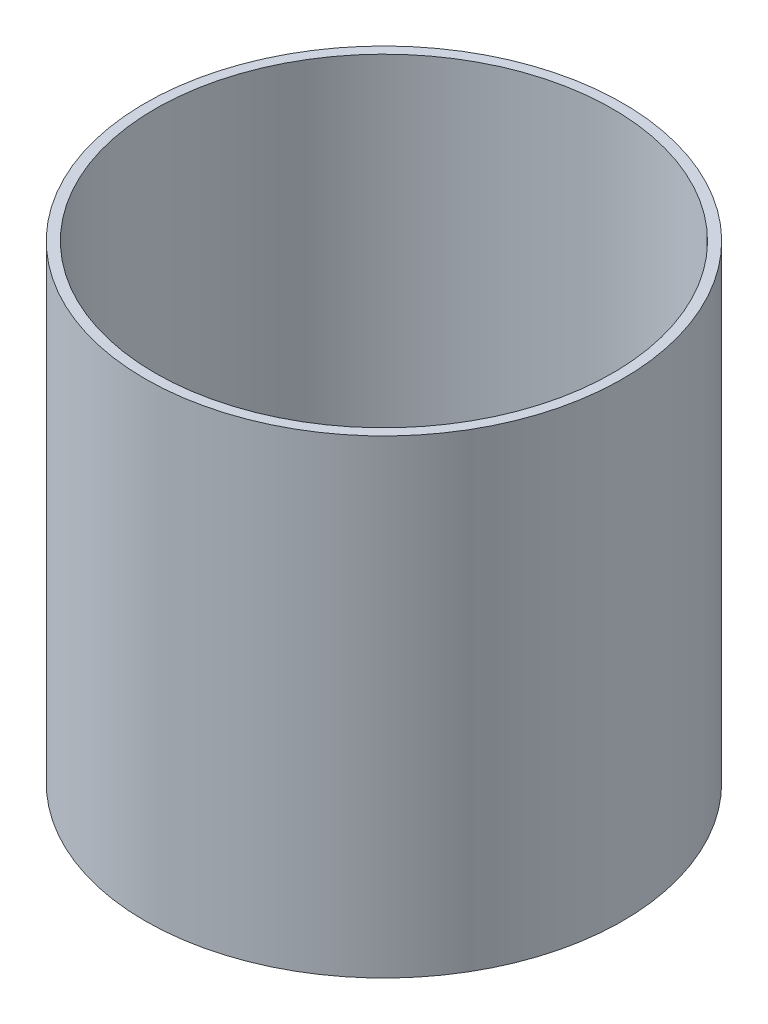
from build123d import *

# Parameters (mm, degrees)
SKETCH1_R           = 22
SKETCH1_R_2         = 21.08
BOSS_EXTRUDE1_DEPTH = 43.25


with BuildPart() as part:
    # Sketch1 → Boss-Extrude1 (new body)
    with BuildSketch(Plane(origin=(0, 0, 0), x_dir=(1, 0, 0), z_dir=(0, 1, 0))):
        Circle(SKETCH1_R)
        Circle(SKETCH1_R_2, mode=Mode.SUBTRACT)
    extrude(amount=BOSS_EXTRUDE1_DEPTH)


solid = part.part
